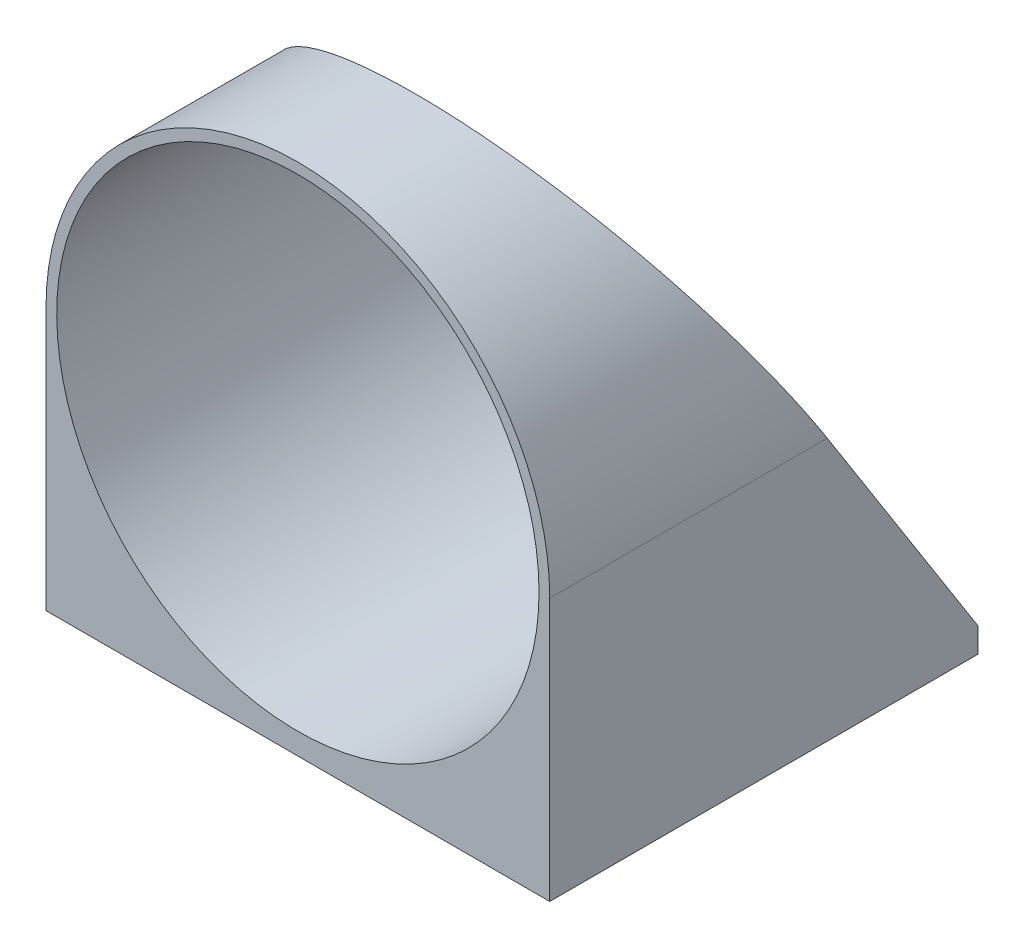
from build123d import *

# Parameters (mm, degrees)
BOSS_EXTRUDE1_START     = -856.54016
SKETCH1_R               = 23.525
SKETCH1_R_2             = 22.525
BOSS_EXTRUDE1_DEPTH     = 40
BOSS_EXTRUDE2_DEPTH     = 40
CUT_EXTRUDE1_DEPTH      = 24.525
CUT_EXTRUDE1_DEPTH_BACK = 24.525


with BuildPart() as part:
    # Sketch1 → Boss-Extrude1 (new body)
    with BuildSketch(Plane.XY.offset(BOSS_EXTRUDE1_START)):
        Circle(SKETCH1_R)
        Circle(SKETCH1_R_2, mode=Mode.SUBTRACT)
    extrude(amount=BOSS_EXTRUDE1_DEPTH)

    # Sketch4 → Boss-Extrude2 (add)
    with BuildSketch(Plane.XY.offset(-816.540159845)):
        Polygon((23.525, -23.525), (23.525, -24.525), (-23.525, -24.525), (-23.525, -23.525), (0, -23.525), align=None)
        with BuildLine():
            Line((23.525, -23.525), (23.525, 0))
            ThreePointArc((23.525, 0), (16.634687027, -16.634687027), (0, -23.525))
            Line((0, -23.525), (23.525, -23.525))
        make_face()
        with BuildLine():
            ThreePointArc((0, -23.525), (-16.634687027, -16.634687027), (-23.525, 0))
            Line((-23.525, 0), (-23.525, -23.525))
            Line((-23.525, -23.525), (0, -23.525))
        make_face()
    extrude(amount=-BOSS_EXTRUDE2_DEPTH)

    # Sketch3 → Cut-Extrude1 (cut, two sides)
    with BuildSketch(Plane(origin=(0, 0, 0), x_dir=(0, 0, -1), z_dir=(1, 0, 0))) as cut_extrude1_sk:
        Polygon((827.542837087, 23.525), (856.540159845, -22.225), (856.540159845, 23.525), align=None)
    extrude(amount=CUT_EXTRUDE1_DEPTH, mode=Mode.SUBTRACT)
    extrude(cut_extrude1_sk.sketch, amount=-CUT_EXTRUDE1_DEPTH_BACK, mode=Mode.SUBTRACT)


solid = part.part
